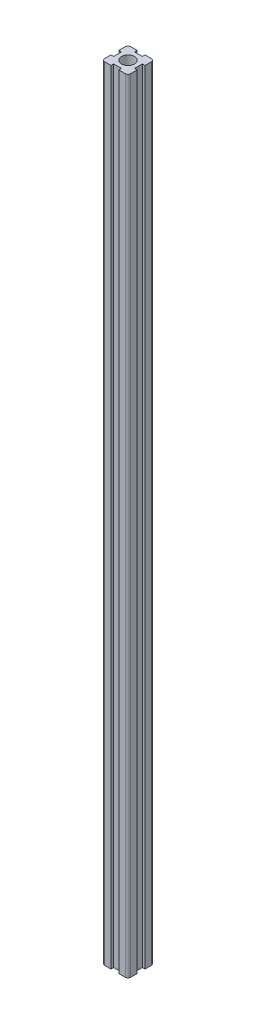
from build123d import *

# Parameters (mm, degrees)
SKETCH1_W           = 20
SKETCH1_H           = 20
SKETCH1_R           = 5
BOSS_EXTRUDE2_DEPTH = 300
SKETCH2_W           = 6
SKETCH2_H           = 4
SKETCH2_W_2         = 4
SKETCH2_H_2         = 6
CUT_EXTRUDE1_DEPTH  = 600
FILLET1_R           = 2


with BuildPart() as part:
    # Sketch1 → Boss-Extrude2 (new body, symmetric)
    with BuildSketch(Plane(origin=(0, 0, 0), x_dir=(1, 0, 0), z_dir=(0, 1, 0))):
        Rectangle(SKETCH1_W, SKETCH1_H)
        Circle(SKETCH1_R, mode=Mode.SUBTRACT)
    extrude(amount=BOSS_EXTRUDE2_DEPTH, both=True)

    # Sketch2 → Cut-Extrude1 (cut)
    with BuildSketch(Plane.XZ.offset(300)):
        with Locations((0, 10)):
            Rectangle(SKETCH2_W, SKETCH2_H)
        with Locations((10, 0)):
            Rectangle(SKETCH2_W_2, SKETCH2_H_2)
        with Locations((0, -10)):
            Rectangle(SKETCH2_W, SKETCH2_H)
        with Locations((-10, 0)):
            Rectangle(SKETCH2_W_2, SKETCH2_H_2)
    extrude(amount=-CUT_EXTRUDE1_DEPTH, mode=Mode.SUBTRACT)

    # Fillet1
    fillet1_edges = [part.edges().sort_by_distance(p)[0] for p in [
        (10, 0, 10),
        (-10, 0, 10),
        (-10, 0, -10),
        (10, 0, -10),
    ]]
    fillet(fillet1_edges, radius=FILLET1_R)


solid = part.part
